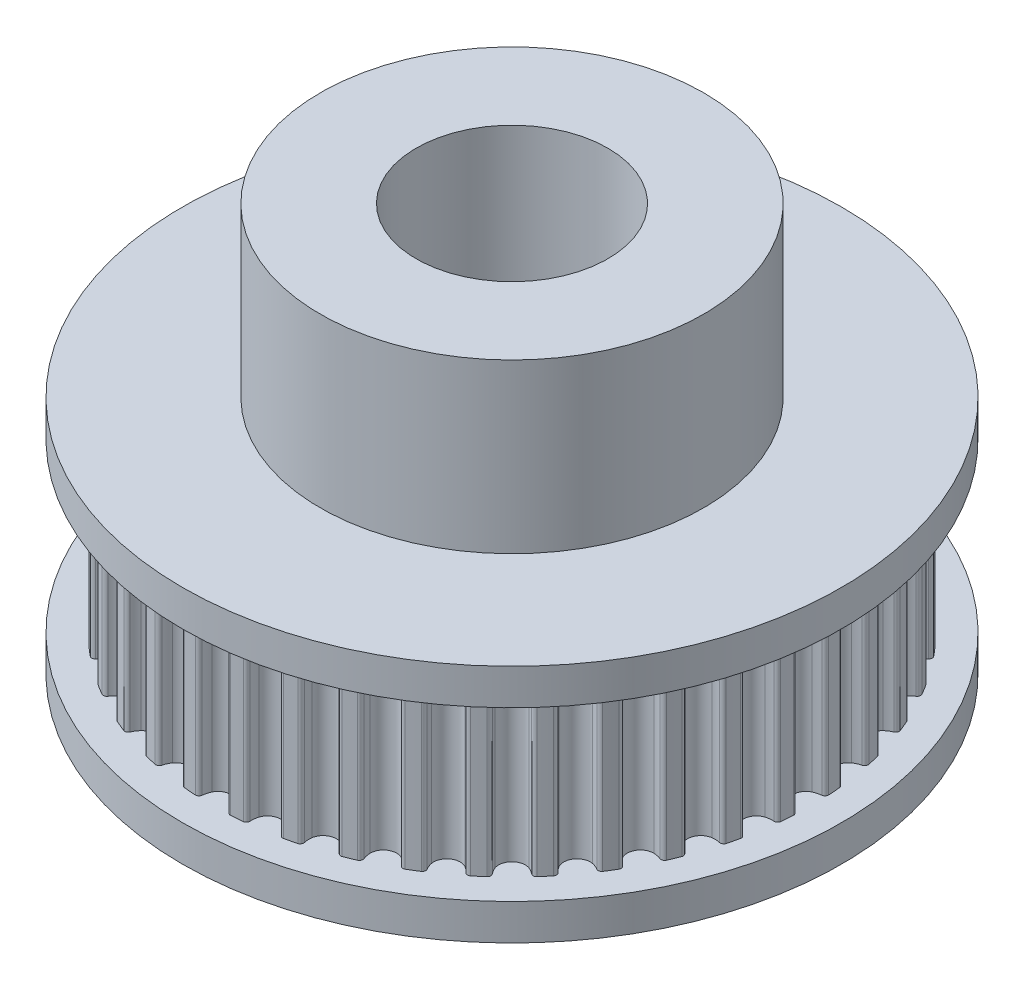
from build123d import *

# Parameters (mm, degrees)
SKETCH2_R           = 4
BOSS_EXTRUDE1_DEPTH = 7


with BuildPart() as part:
    # Sketch1 → Revolve1 (revolve)
    with BuildSketch(Plane.XY):
        Polygon((4, 0), (4, 17), (8, 17), (8, 10), (13.75, 10), (13.75, 8.5), (9.193020022, 8.5), (9.193020022, 1.5), (13.75, 1.5), (13.75, 0), align=None)
    revolve(axis=Axis((0, 0, 0), (0, 1, 0)))

    # Sketch2 → Boss-Extrude1 (add)
    with BuildSketch(Plane(origin=(0, 1.5, 0), x_dir=(1, 0, 0), z_dir=(0, 1, 0))):
        with BuildLine():
            ThreePointArc((12.479630426, -0.730339012), (12.442347251, -0.63136985), (12.349031565, -0.581599248))
            ThreePointArc((12.349031565, -0.581599248), (12.183508148, -0.552656072), (12.025167851, -0.496406098))
            ThreePointArc((12.025167851, -0.496406098), (11.801260646, -0.291780184), (11.718372011, 0))
            ThreePointArc((11.718372011, 0), (11.801260646, 0.291780184), (12.025167851, 0.496406098))
            ThreePointArc((12.025167851, 0.496406098), (12.183508148, 0.552656072), (12.349031565, 0.581599248))
            ThreePointArc((12.349031565, 0.581599248), (12.442347251, 0.63136985), (12.479630426, 0.730339012))
            ThreePointArc((12.479630426, 0.730339012), (12.462450985, 0.980816164), (12.44023566, 1.230896983))
            ThreePointArc((12.44023566, 1.230896983), (12.387929315, 1.322815296), (12.287976662, 1.357375351))
            ThreePointArc((12.287976662, 1.357375351), (12.119963402, 1.360068621), (11.954773103, 1.390856184))
            ThreePointArc((11.954773103, 1.390856184), (11.701612021, 1.557936011), (11.574099406, 1.833157257))
            ThreePointArc((11.574099406, 1.833157257), (11.610323068, 2.134311781), (11.799463058, 2.371445215))
            ThreePointArc((11.799463058, 2.371445215), (11.947054488, 2.451772538), (12.106012327, 2.506252943))
            ThreePointArc((12.106012327, 2.506252943), (12.190393305, 2.570008576), (12.211735274, 2.673591637))
            ThreePointArc((12.211735274, 2.673591637), (12.155584081, 2.918297542), (12.094521004, 3.161824209))
            ThreePointArc((12.094521004, 3.161824209), (12.028479445, 3.24442834), (11.924350992, 3.262926863))
            ThreePointArc((11.924350992, 3.262926863), (11.757984934, 3.23930391), (11.590012165, 3.243870972))
            ThreePointArc((11.590012165, 3.243870972), (11.313830873, 3.36929065), (11.144834061, 3.621176098))
            ThreePointArc((11.144834061, 3.621176098), (11.133500803, 3.92428954), (11.283216324, 4.188091481))
            ThreePointArc((11.283216324, 4.188091481), (11.416424697, 4.290518228), (11.564902888, 4.369194372))
            ThreePointArc((11.564902888, 4.369194372), (11.638271418, 4.445365161), (11.643146672, 4.551011562))
            ThreePointArc((11.643146672, 4.551011562), (11.549406355, 4.78392075), (11.450999102, 5.014896829))
            ThreePointArc((11.450999102, 5.014896829), (11.372848491, 5.086152791), (11.267108225, 5.088134287))
            ThreePointArc((11.267108225, 5.088134287), (11.106485854, 5.038776787), (10.939866663, 5.01701089))
            ThreePointArc((10.939866663, 5.01701089), (10.647465661, 5.097682171), (10.441145914, 5.320029565))
            ThreePointArc((10.441145914, 5.320029565), (10.382534798, 5.617638266), (10.489139358, 5.901613034))
            ThreePointArc((10.489139358, 5.901613034), (10.604684641, 6.023617119), (10.739027159, 6.124551736))
            ThreePointArc((10.739027159, 6.124551736), (10.799576663, 6.211262102), (10.787865156, 6.316370479))
            ThreePointArc((10.787865156, 6.316370479), (10.658843915, 6.531747952), (10.525515599, 6.744486046))
            ThreePointArc((10.525515599, 6.744486046), (10.437180263, 6.80263928), (10.332431861, 6.788054959))
            ThreePointArc((10.332431861, 6.788054959), (10.181508232, 6.714178256), (10.020345336, 6.66661535))
            ThreePointArc((10.020345336, 6.66661535), (9.718924507, 6.700551839), (9.480362103, 6.887886249))
            ThreePointArc((9.480362103, 6.887886249), (9.375916329, 7.172662093), (9.436784968, 7.469817289))
            ThreePointArc((9.436784968, 7.469817289), (9.531822054, 7.608394565), (9.64872094, 7.72910231))
            ThreePointArc((9.64872094, 7.72910231), (9.694960489, 7.824217157), (9.666950598, 7.926199391))
            ThreePointArc((9.666950598, 7.926199391), (9.505825362, 8.118741841), (9.340858969, 8.308003633))
            ThreePointArc((9.340858969, 8.308003633), (9.244514018, 8.351622213), (9.143336733, 8.320831189))
            ThreePointArc((9.143336733, 8.320831189), (9.005828086, 8.224254374), (8.854089851, 8.152065614))
            ThreePointArc((8.854089851, 8.152065614), (8.551071176, 8.138431683), (8.286140313, 8.286140313))
            ThreePointArc((8.286140313, 8.286140313), (8.138431683, 8.551071176), (8.152065614, 8.854089851))
            ThreePointArc((8.152065614, 8.854089851), (8.224254374, 9.005828086), (8.320831189, 9.143336733))
            ThreePointArc((8.320831189, 9.143336733), (8.351622213, 9.244514018), (8.308003633, 9.340858969))
            ThreePointArc((8.308003633, 9.340858969), (8.118741841, 9.505825362), (7.926199391, 9.666950598))
            ThreePointArc((7.926199391, 9.666950598), (7.824217157, 9.694960489), (7.72910231, 9.64872094))
            ThreePointArc((7.72910231, 9.64872094), (7.608394565, 9.531822054), (7.469817289, 9.436784968))
            ThreePointArc((7.469817289, 9.436784968), (7.172662093, 9.375916329), (6.887886249, 9.480362103))
            ThreePointArc((6.887886249, 9.480362103), (6.700551839, 9.718924507), (6.66661535, 10.020345336))
            ThreePointArc((6.66661535, 10.020345336), (6.714178256, 10.181508232), (6.788054959, 10.332431861))
            ThreePointArc((6.788054959, 10.332431861), (6.80263928, 10.437180263), (6.744486046, 10.525515599))
            ThreePointArc((6.744486046, 10.525515599), (6.531747952, 10.658843915), (6.316370479, 10.787865156))
            ThreePointArc((6.316370479, 10.787865156), (6.211262102, 10.799576663), (6.124551736, 10.739027159))
            ThreePointArc((6.124551736, 10.739027159), (6.023617119, 10.604684641), (5.901613034, 10.489139358))
            ThreePointArc((5.901613034, 10.489139358), (5.617638266, 10.382534798), (5.320029565, 10.441145914))
            ThreePointArc((5.320029565, 10.441145914), (5.097682171, 10.647465661), (5.01701089, 10.939866663))
            ThreePointArc((5.01701089, 10.939866663), (5.038776787, 11.106485854), (5.088134287, 11.267108225))
            ThreePointArc((5.088134287, 11.267108225), (5.086152791, 11.372848491), (5.014896829, 11.450999102))
            ThreePointArc((5.014896829, 11.450999102), (4.78392075, 11.549406355), (4.551011562, 11.643146672))
            ThreePointArc((4.551011562, 11.643146672), (4.445365161, 11.638271418), (4.369194372, 11.564902888))
            ThreePointArc((4.369194372, 11.564902888), (4.290518228, 11.416424697), (4.188091481, 11.283216324))
            ThreePointArc((4.188091481, 11.283216324), (3.92428954, 11.133500803), (3.621176098, 11.144834061))
            ThreePointArc((3.621176098, 11.144834061), (3.36929065, 11.313830873), (3.243870972, 11.590012165))
            ThreePointArc((3.243870972, 11.590012165), (3.23930391, 11.757984934), (3.262926863, 11.924350992))
            ThreePointArc((3.262926863, 11.924350992), (3.24442834, 12.028479445), (3.161824209, 12.094521004))
            ThreePointArc((3.161824209, 12.094521004), (2.918297542, 12.155584081), (2.673591637, 12.211735274))
            ThreePointArc((2.673591637, 12.211735274), (2.570008576, 12.190393305), (2.506252943, 12.106012327))
            ThreePointArc((2.506252943, 12.106012327), (2.451772538, 11.947054488), (2.371445215, 11.799463058))
            ThreePointArc((2.371445215, 11.799463058), (2.134311781, 11.610323068), (1.833157257, 11.574099406))
            ThreePointArc((1.833157257, 11.574099406), (1.557936011, 11.701612021), (1.390856184, 11.954773103))
            ThreePointArc((1.390856184, 11.954773103), (1.360068621, 12.119963402), (1.357375351, 12.287976662))
            ThreePointArc((1.357375351, 12.287976662), (1.322815296, 12.387929315), (1.230896983, 12.44023566))
            ThreePointArc((1.230896983, 12.44023566), (0.980816164, 12.462450985), (0.730339012, 12.479630426))
            ThreePointArc((0.730339012, 12.479630426), (0.63136985, 12.442347251), (0.581599248, 12.349031565))
            ThreePointArc((0.581599248, 12.349031565), (0.552656072, 12.183508148), (0.496406098, 12.025167851))
            ThreePointArc((0.496406098, 12.025167851), (0.291780184, 11.801260646), (0, 11.718372011))
            ThreePointArc((0, 11.718372011), (-0.291780184, 11.801260646), (-0.496406098, 12.025167851))
            ThreePointArc((-0.496406098, 12.025167851), (-0.552656072, 12.183508148), (-0.581599248, 12.349031565))
            ThreePointArc((-0.581599248, 12.349031565), (-0.63136985, 12.442347251), (-0.730339012, 12.479630426))
            ThreePointArc((-0.730339012, 12.479630426), (-0.980816164, 12.462450985), (-1.230896983, 12.44023566))
            ThreePointArc((-1.230896983, 12.44023566), (-1.322815296, 12.387929315), (-1.357375351, 12.287976662))
            ThreePointArc((-1.357375351, 12.287976662), (-1.360068621, 12.119963402), (-1.390856184, 11.954773103))
            ThreePointArc((-1.390856184, 11.954773103), (-1.557936011, 11.701612021), (-1.833157257, 11.574099406))
            ThreePointArc((-1.833157257, 11.574099406), (-2.134311781, 11.610323068), (-2.371445215, 11.799463058))
            ThreePointArc((-2.371445215, 11.799463058), (-2.451772538, 11.947054488), (-2.506252943, 12.106012327))
            ThreePointArc((-2.506252943, 12.106012327), (-2.570008576, 12.190393305), (-2.673591637, 12.211735274))
            ThreePointArc((-2.673591637, 12.211735274), (-2.918297542, 12.155584081), (-3.161824209, 12.094521004))
            ThreePointArc((-3.161824209, 12.094521004), (-3.24442834, 12.028479445), (-3.262926863, 11.924350992))
            ThreePointArc((-3.262926863, 11.924350992), (-3.23930391, 11.757984934), (-3.243870972, 11.590012165))
            ThreePointArc((-3.243870972, 11.590012165), (-3.36929065, 11.313830873), (-3.621176098, 11.144834061))
            ThreePointArc((-3.621176098, 11.144834061), (-3.92428954, 11.133500803), (-4.188091481, 11.283216324))
            ThreePointArc((-4.188091481, 11.283216324), (-4.290518228, 11.416424697), (-4.369194372, 11.564902888))
            ThreePointArc((-4.369194372, 11.564902888), (-4.445365161, 11.638271418), (-4.551011562, 11.643146672))
            ThreePointArc((-4.551011562, 11.643146672), (-4.78392075, 11.549406355), (-5.014896829, 11.450999102))
            ThreePointArc((-5.014896829, 11.450999102), (-5.086152791, 11.372848491), (-5.088134287, 11.267108225))
            ThreePointArc((-5.088134287, 11.267108225), (-5.038776787, 11.106485854), (-5.01701089, 10.939866663))
            ThreePointArc((-5.01701089, 10.939866663), (-5.097682171, 10.647465661), (-5.320029565, 10.441145914))
            ThreePointArc((-5.320029565, 10.441145914), (-5.617638266, 10.382534798), (-5.901613034, 10.489139358))
            ThreePointArc((-5.901613034, 10.489139358), (-6.023617119, 10.604684641), (-6.124551736, 10.739027159))
            ThreePointArc((-6.124551736, 10.739027159), (-6.211262102, 10.799576663), (-6.316370479, 10.787865156))
            ThreePointArc((-6.316370479, 10.787865156), (-6.531747952, 10.658843915), (-6.744486046, 10.525515599))
            ThreePointArc((-6.744486046, 10.525515599), (-6.80263928, 10.437180263), (-6.788054959, 10.332431861))
            ThreePointArc((-6.788054959, 10.332431861), (-6.714178256, 10.181508232), (-6.66661535, 10.020345336))
            ThreePointArc((-6.66661535, 10.020345336), (-6.700551839, 9.718924507), (-6.887886249, 9.480362103))
            ThreePointArc((-6.887886249, 9.480362103), (-7.172662093, 9.375916329), (-7.469817289, 9.436784968))
            ThreePointArc((-7.469817289, 9.436784968), (-7.608394565, 9.531822054), (-7.72910231, 9.64872094))
            ThreePointArc((-7.72910231, 9.64872094), (-7.824217157, 9.694960489), (-7.926199391, 9.666950598))
            ThreePointArc((-7.926199391, 9.666950598), (-8.118741841, 9.505825362), (-8.308003633, 9.340858969))
            ThreePointArc((-8.308003633, 9.340858969), (-8.351622213, 9.244514018), (-8.320831189, 9.143336733))
            ThreePointArc((-8.320831189, 9.143336733), (-8.224254374, 9.005828086), (-8.152065614, 8.854089851))
            ThreePointArc((-8.152065614, 8.854089851), (-8.138431683, 8.551071176), (-8.286140313, 8.286140313))
            ThreePointArc((-8.286140313, 8.286140313), (-8.551071176, 8.138431683), (-8.854089851, 8.152065614))
            ThreePointArc((-8.854089851, 8.152065614), (-9.005828086, 8.224254374), (-9.143336733, 8.320831189))
            ThreePointArc((-9.143336733, 8.320831189), (-9.244514018, 8.351622213), (-9.340858969, 8.308003633))
            ThreePointArc((-9.340858969, 8.308003633), (-9.505825362, 8.118741841), (-9.666950598, 7.926199391))
            ThreePointArc((-9.666950598, 7.926199391), (-9.694960489, 7.824217157), (-9.64872094, 7.72910231))
            ThreePointArc((-9.64872094, 7.72910231), (-9.531822054, 7.608394565), (-9.436784968, 7.469817289))
            ThreePointArc((-9.436784968, 7.469817289), (-9.375916329, 7.172662093), (-9.480362103, 6.887886249))
            ThreePointArc((-9.480362103, 6.887886249), (-9.718924507, 6.700551839), (-10.020345336, 6.66661535))
            ThreePointArc((-10.020345336, 6.66661535), (-10.181508232, 6.714178256), (-10.332431861, 6.788054959))
            ThreePointArc((-10.332431861, 6.788054959), (-10.437180263, 6.80263928), (-10.525515599, 6.744486046))
            ThreePointArc((-10.525515599, 6.744486046), (-10.658843915, 6.531747952), (-10.787865156, 6.316370479))
            ThreePointArc((-10.787865156, 6.316370479), (-10.799576663, 6.211262102), (-10.739027159, 6.124551736))
            ThreePointArc((-10.739027159, 6.124551736), (-10.604684641, 6.023617119), (-10.489139358, 5.901613034))
            ThreePointArc((-10.489139358, 5.901613034), (-10.382534798, 5.617638266), (-10.441145914, 5.320029565))
            ThreePointArc((-10.441145914, 5.320029565), (-10.647465661, 5.097682171), (-10.939866663, 5.01701089))
            ThreePointArc((-10.939866663, 5.01701089), (-11.106485854, 5.038776787), (-11.267108225, 5.088134287))
            ThreePointArc((-11.267108225, 5.088134287), (-11.372848491, 5.086152791), (-11.450999102, 5.014896829))
            ThreePointArc((-11.450999102, 5.014896829), (-11.549406355, 4.78392075), (-11.643146672, 4.551011562))
            ThreePointArc((-11.643146672, 4.551011562), (-11.638271418, 4.445365161), (-11.564902888, 4.369194372))
            ThreePointArc((-11.564902888, 4.369194372), (-11.416424697, 4.290518228), (-11.283216324, 4.188091481))
            ThreePointArc((-11.283216324, 4.188091481), (-11.133500803, 3.92428954), (-11.144834061, 3.621176098))
            ThreePointArc((-11.144834061, 3.621176098), (-11.313830873, 3.36929065), (-11.590012165, 3.243870972))
            ThreePointArc((-11.590012165, 3.243870972), (-11.757984934, 3.23930391), (-11.924350992, 3.262926863))
            ThreePointArc((-11.924350992, 3.262926863), (-12.028479445, 3.24442834), (-12.094521004, 3.161824209))
            ThreePointArc((-12.094521004, 3.161824209), (-12.155584081, 2.918297542), (-12.211735274, 2.673591637))
            ThreePointArc((-12.211735274, 2.673591637), (-12.190393305, 2.570008576), (-12.106012327, 2.506252943))
            ThreePointArc((-12.106012327, 2.506252943), (-11.947054488, 2.451772538), (-11.799463058, 2.371445215))
            ThreePointArc((-11.799463058, 2.371445215), (-11.610323068, 2.134311781), (-11.574099406, 1.833157257))
            ThreePointArc((-11.574099406, 1.833157257), (-11.701612021, 1.557936011), (-11.954773103, 1.390856184))
            ThreePointArc((-11.954773103, 1.390856184), (-12.119963402, 1.360068621), (-12.287976662, 1.357375351))
            ThreePointArc((-12.287976662, 1.357375351), (-12.387929315, 1.322815296), (-12.44023566, 1.230896983))
            ThreePointArc((-12.44023566, 1.230896983), (-12.462450985, 0.980816164), (-12.479630426, 0.730339012))
            ThreePointArc((-12.479630426, 0.730339012), (-12.442347251, 0.63136985), (-12.349031565, 0.581599248))
            ThreePointArc((-12.349031565, 0.581599248), (-12.183508148, 0.552656072), (-12.025167851, 0.496406098))
            ThreePointArc((-12.025167851, 0.496406098), (-11.801260646, 0.291780184), (-11.718372011, 0))
            ThreePointArc((-11.718372011, 0), (-11.801260646, -0.291780184), (-12.025167851, -0.496406098))
            ThreePointArc((-12.025167851, -0.496406098), (-12.183508148, -0.552656072), (-12.349031565, -0.581599248))
            ThreePointArc((-12.349031565, -0.581599248), (-12.442347251, -0.63136985), (-12.479630426, -0.730339012))
            ThreePointArc((-12.479630426, -0.730339012), (-12.462450985, -0.980816164), (-12.44023566, -1.230896983))
            ThreePointArc((-12.44023566, -1.230896983), (-12.387929315, -1.322815296), (-12.287976662, -1.357375351))
            ThreePointArc((-12.287976662, -1.357375351), (-12.119963402, -1.360068621), (-11.954773103, -1.390856184))
            ThreePointArc((-11.954773103, -1.390856184), (-11.701612021, -1.557936011), (-11.574099406, -1.833157257))
            ThreePointArc((-11.574099406, -1.833157257), (-11.610323068, -2.134311781), (-11.799463058, -2.371445215))
            ThreePointArc((-11.799463058, -2.371445215), (-11.947054488, -2.451772538), (-12.106012327, -2.506252943))
            ThreePointArc((-12.106012327, -2.506252943), (-12.190393305, -2.570008576), (-12.211735274, -2.673591637))
            ThreePointArc((-12.211735274, -2.673591637), (-12.155584081, -2.918297542), (-12.094521004, -3.161824209))
            ThreePointArc((-12.094521004, -3.161824209), (-12.028479445, -3.24442834), (-11.924350992, -3.262926863))
            ThreePointArc((-11.924350992, -3.262926863), (-11.757984934, -3.23930391), (-11.590012165, -3.243870972))
            ThreePointArc((-11.590012165, -3.243870972), (-11.313830873, -3.36929065), (-11.144834061, -3.621176098))
            ThreePointArc((-11.144834061, -3.621176098), (-11.133500803, -3.92428954), (-11.283216324, -4.188091481))
            ThreePointArc((-11.283216324, -4.188091481), (-11.416424697, -4.290518228), (-11.564902888, -4.369194372))
            ThreePointArc((-11.564902888, -4.369194372), (-11.638271418, -4.445365161), (-11.643146672, -4.551011562))
            ThreePointArc((-11.643146672, -4.551011562), (-11.549406355, -4.78392075), (-11.450999102, -5.014896829))
            ThreePointArc((-11.450999102, -5.014896829), (-11.372848491, -5.086152791), (-11.267108225, -5.088134287))
            ThreePointArc((-11.267108225, -5.088134287), (-11.106485854, -5.038776787), (-10.939866663, -5.01701089))
            ThreePointArc((-10.939866663, -5.01701089), (-10.647465661, -5.097682171), (-10.441145914, -5.320029565))
            ThreePointArc((-10.441145914, -5.320029565), (-10.382534798, -5.617638266), (-10.489139358, -5.901613034))
            ThreePointArc((-10.489139358, -5.901613034), (-10.604684641, -6.023617119), (-10.739027159, -6.124551736))
            ThreePointArc((-10.739027159, -6.124551736), (-10.799576663, -6.211262102), (-10.787865156, -6.316370479))
            ThreePointArc((-10.787865156, -6.316370479), (-10.658843915, -6.531747952), (-10.525515599, -6.744486046))
            ThreePointArc((-10.525515599, -6.744486046), (-10.437180263, -6.80263928), (-10.332431861, -6.788054959))
            ThreePointArc((-10.332431861, -6.788054959), (-10.181508232, -6.714178256), (-10.020345336, -6.66661535))
            ThreePointArc((-10.020345336, -6.66661535), (-9.718924507, -6.700551839), (-9.480362103, -6.887886249))
            ThreePointArc((-9.480362103, -6.887886249), (-9.375916329, -7.172662093), (-9.436784968, -7.469817289))
            ThreePointArc((-9.436784968, -7.469817289), (-9.531822054, -7.608394565), (-9.64872094, -7.72910231))
            ThreePointArc((-9.64872094, -7.72910231), (-9.694960489, -7.824217157), (-9.666950598, -7.926199391))
            ThreePointArc((-9.666950598, -7.926199391), (-9.505825362, -8.118741841), (-9.340858969, -8.308003633))
            ThreePointArc((-9.340858969, -8.308003633), (-9.244514018, -8.351622213), (-9.143336733, -8.320831189))
            ThreePointArc((-9.143336733, -8.320831189), (-9.005828086, -8.224254374), (-8.854089851, -8.152065614))
            ThreePointArc((-8.854089851, -8.152065614), (-8.551071176, -8.138431683), (-8.286140313, -8.286140313))
            ThreePointArc((-8.286140313, -8.286140313), (-8.138431683, -8.551071176), (-8.152065614, -8.854089851))
            ThreePointArc((-8.152065614, -8.854089851), (-8.224254374, -9.005828086), (-8.320831189, -9.143336733))
            ThreePointArc((-8.320831189, -9.143336733), (-8.351622213, -9.244514018), (-8.308003633, -9.340858969))
            ThreePointArc((-8.308003633, -9.340858969), (-8.118741841, -9.505825362), (-7.926199391, -9.666950598))
            ThreePointArc((-7.926199391, -9.666950598), (-7.824217157, -9.694960489), (-7.72910231, -9.64872094))
            ThreePointArc((-7.72910231, -9.64872094), (-7.608394565, -9.531822054), (-7.469817289, -9.436784968))
            ThreePointArc((-7.469817289, -9.436784968), (-7.172662093, -9.375916329), (-6.887886249, -9.480362103))
            ThreePointArc((-6.887886249, -9.480362103), (-6.700551839, -9.718924507), (-6.66661535, -10.020345336))
            ThreePointArc((-6.66661535, -10.020345336), (-6.714178256, -10.181508232), (-6.788054959, -10.332431861))
            ThreePointArc((-6.788054959, -10.332431861), (-6.80263928, -10.437180263), (-6.744486046, -10.525515599))
            ThreePointArc((-6.744486046, -10.525515599), (-6.531747952, -10.658843915), (-6.316370479, -10.787865156))
            ThreePointArc((-6.316370479, -10.787865156), (-6.211262102, -10.799576663), (-6.124551736, -10.739027159))
            ThreePointArc((-6.124551736, -10.739027159), (-6.023617119, -10.604684641), (-5.901613034, -10.489139358))
            ThreePointArc((-5.901613034, -10.489139358), (-5.617638266, -10.382534798), (-5.320029565, -10.441145914))
            ThreePointArc((-5.320029565, -10.441145914), (-5.097682171, -10.647465661), (-5.01701089, -10.939866663))
            ThreePointArc((-5.01701089, -10.939866663), (-5.038776787, -11.106485854), (-5.088134287, -11.267108225))
            ThreePointArc((-5.088134287, -11.267108225), (-5.086152791, -11.372848491), (-5.014896829, -11.450999102))
            ThreePointArc((-5.014896829, -11.450999102), (-4.78392075, -11.549406355), (-4.551011562, -11.643146672))
            ThreePointArc((-4.551011562, -11.643146672), (-4.445365161, -11.638271418), (-4.369194372, -11.564902888))
            ThreePointArc((-4.369194372, -11.564902888), (-4.290518228, -11.416424697), (-4.188091481, -11.283216324))
            ThreePointArc((-4.188091481, -11.283216324), (-3.92428954, -11.133500803), (-3.621176098, -11.144834061))
            ThreePointArc((-3.621176098, -11.144834061), (-3.36929065, -11.313830873), (-3.243870972, -11.590012165))
            ThreePointArc((-3.243870972, -11.590012165), (-3.23930391, -11.757984934), (-3.262926863, -11.924350992))
            ThreePointArc((-3.262926863, -11.924350992), (-3.24442834, -12.028479445), (-3.161824209, -12.094521004))
            ThreePointArc((-3.161824209, -12.094521004), (-2.918297542, -12.155584081), (-2.673591637, -12.211735274))
            ThreePointArc((-2.673591637, -12.211735274), (-2.570008576, -12.190393305), (-2.506252943, -12.106012327))
            ThreePointArc((-2.506252943, -12.106012327), (-2.451772538, -11.947054488), (-2.371445215, -11.799463058))
            ThreePointArc((-2.371445215, -11.799463058), (-2.134311781, -11.610323068), (-1.833157257, -11.574099406))
            ThreePointArc((-1.833157257, -11.574099406), (-1.557936011, -11.701612021), (-1.390856184, -11.954773103))
            ThreePointArc((-1.390856184, -11.954773103), (-1.360068621, -12.119963402), (-1.357375351, -12.287976662))
            ThreePointArc((-1.357375351, -12.287976662), (-1.322815296, -12.387929315), (-1.230896983, -12.44023566))
            ThreePointArc((-1.230896983, -12.44023566), (-0.980816164, -12.462450985), (-0.730339012, -12.479630426))
            ThreePointArc((-0.730339012, -12.479630426), (-0.63136985, -12.442347251), (-0.581599248, -12.349031565))
            ThreePointArc((-0.581599248, -12.349031565), (-0.552656072, -12.183508148), (-0.496406098, -12.025167851))
            ThreePointArc((-0.496406098, -12.025167851), (-0.291780184, -11.801260646), (0, -11.718372011))
            ThreePointArc((0, -11.718372011), (0.291780184, -11.801260646), (0.496406098, -12.025167851))
            ThreePointArc((0.496406098, -12.025167851), (0.552656072, -12.183508148), (0.581599248, -12.349031565))
            ThreePointArc((0.581599248, -12.349031565), (0.63136985, -12.442347251), (0.730339012, -12.479630426))
            ThreePointArc((0.730339012, -12.479630426), (0.980816164, -12.462450985), (1.230896983, -12.44023566))
            ThreePointArc((1.230896983, -12.44023566), (1.322815296, -12.387929315), (1.357375351, -12.287976662))
            ThreePointArc((1.357375351, -12.287976662), (1.360068621, -12.119963402), (1.390856184, -11.954773103))
            ThreePointArc((1.390856184, -11.954773103), (1.557936011, -11.701612021), (1.833157257, -11.574099406))
            ThreePointArc((1.833157257, -11.574099406), (2.134311781, -11.610323068), (2.371445215, -11.799463058))
            ThreePointArc((2.371445215, -11.799463058), (2.451772538, -11.947054488), (2.506252943, -12.106012327))
            ThreePointArc((2.506252943, -12.106012327), (2.570008576, -12.190393305), (2.673591637, -12.211735274))
            ThreePointArc((2.673591637, -12.211735274), (2.918297542, -12.155584081), (3.161824209, -12.094521004))
            ThreePointArc((3.161824209, -12.094521004), (3.24442834, -12.028479445), (3.262926863, -11.924350992))
            ThreePointArc((3.262926863, -11.924350992), (3.23930391, -11.757984934), (3.243870972, -11.590012165))
            ThreePointArc((3.243870972, -11.590012165), (3.36929065, -11.313830873), (3.621176098, -11.144834061))
            ThreePointArc((3.621176098, -11.144834061), (3.92428954, -11.133500803), (4.188091481, -11.283216324))
            ThreePointArc((4.188091481, -11.283216324), (4.290518228, -11.416424697), (4.369194372, -11.564902888))
            ThreePointArc((4.369194372, -11.564902888), (4.445365161, -11.638271418), (4.551011562, -11.643146672))
            ThreePointArc((4.551011562, -11.643146672), (4.78392075, -11.549406355), (5.014896829, -11.450999102))
            ThreePointArc((5.014896829, -11.450999102), (5.086152791, -11.372848491), (5.088134287, -11.267108225))
            ThreePointArc((5.088134287, -11.267108225), (5.038776787, -11.106485854), (5.01701089, -10.939866663))
            ThreePointArc((5.01701089, -10.939866663), (5.097682171, -10.647465661), (5.320029565, -10.441145914))
            ThreePointArc((5.320029565, -10.441145914), (5.617638266, -10.382534798), (5.901613034, -10.489139358))
            ThreePointArc((5.901613034, -10.489139358), (6.023617119, -10.604684641), (6.124551736, -10.739027159))
            ThreePointArc((6.124551736, -10.739027159), (6.211262102, -10.799576663), (6.316370479, -10.787865156))
            ThreePointArc((6.316370479, -10.787865156), (6.531747952, -10.658843915), (6.744486046, -10.525515599))
            ThreePointArc((6.744486046, -10.525515599), (6.80263928, -10.437180263), (6.788054959, -10.332431861))
            ThreePointArc((6.788054959, -10.332431861), (6.714178256, -10.181508232), (6.66661535, -10.020345336))
            ThreePointArc((6.66661535, -10.020345336), (6.700551839, -9.718924507), (6.887886249, -9.480362103))
            ThreePointArc((6.887886249, -9.480362103), (7.172662093, -9.375916329), (7.469817289, -9.436784968))
            ThreePointArc((7.469817289, -9.436784968), (7.608394565, -9.531822054), (7.72910231, -9.64872094))
            ThreePointArc((7.72910231, -9.64872094), (7.824217157, -9.694960489), (7.926199391, -9.666950598))
            ThreePointArc((7.926199391, -9.666950598), (8.118741841, -9.505825362), (8.308003633, -9.340858969))
            ThreePointArc((8.308003633, -9.340858969), (8.351622213, -9.244514018), (8.320831189, -9.143336733))
            ThreePointArc((8.320831189, -9.143336733), (8.224254374, -9.005828086), (8.152065614, -8.854089851))
            ThreePointArc((8.152065614, -8.854089851), (8.138431683, -8.551071176), (8.286140313, -8.286140313))
            ThreePointArc((8.286140313, -8.286140313), (8.551071176, -8.138431683), (8.854089851, -8.152065614))
            ThreePointArc((8.854089851, -8.152065614), (9.005828086, -8.224254374), (9.143336733, -8.320831189))
            ThreePointArc((9.143336733, -8.320831189), (9.244514018, -8.351622213), (9.340858969, -8.308003633))
            ThreePointArc((9.340858969, -8.308003633), (9.505825362, -8.118741841), (9.666950598, -7.926199391))
            ThreePointArc((9.666950598, -7.926199391), (9.694960489, -7.824217157), (9.64872094, -7.72910231))
            ThreePointArc((9.64872094, -7.72910231), (9.531822054, -7.608394565), (9.436784968, -7.469817289))
            ThreePointArc((9.436784968, -7.469817289), (9.375916329, -7.172662093), (9.480362103, -6.887886249))
            ThreePointArc((9.480362103, -6.887886249), (9.718924507, -6.700551839), (10.020345336, -6.66661535))
            ThreePointArc((10.020345336, -6.66661535), (10.181508232, -6.714178256), (10.332431861, -6.788054959))
            ThreePointArc((10.332431861, -6.788054959), (10.437180263, -6.80263928), (10.525515599, -6.744486046))
            ThreePointArc((10.525515599, -6.744486046), (10.658843915, -6.531747952), (10.787865156, -6.316370479))
            ThreePointArc((10.787865156, -6.316370479), (10.799576663, -6.211262102), (10.739027159, -6.124551736))
            ThreePointArc((10.739027159, -6.124551736), (10.604684641, -6.023617119), (10.489139358, -5.901613034))
            ThreePointArc((10.489139358, -5.901613034), (10.382534798, -5.617638266), (10.441145914, -5.320029565))
            ThreePointArc((10.441145914, -5.320029565), (10.647465661, -5.097682171), (10.939866663, -5.01701089))
            ThreePointArc((10.939866663, -5.01701089), (11.106485854, -5.038776787), (11.267108225, -5.088134287))
            ThreePointArc((11.267108225, -5.088134287), (11.372848491, -5.086152791), (11.450999102, -5.014896829))
            ThreePointArc((11.450999102, -5.014896829), (11.549406355, -4.78392075), (11.643146672, -4.551011562))
            ThreePointArc((11.643146672, -4.551011562), (11.638271418, -4.445365161), (11.564902888, -4.369194372))
            ThreePointArc((11.564902888, -4.369194372), (11.416424697, -4.290518228), (11.283216324, -4.188091481))
            ThreePointArc((11.283216324, -4.188091481), (11.133500803, -3.92428954), (11.144834061, -3.621176098))
            ThreePointArc((11.144834061, -3.621176098), (11.313830873, -3.36929065), (11.590012165, -3.243870972))
            ThreePointArc((11.590012165, -3.243870972), (11.757984934, -3.23930391), (11.924350992, -3.262926863))
            ThreePointArc((11.924350992, -3.262926863), (12.028479445, -3.24442834), (12.094521004, -3.161824209))
            ThreePointArc((12.094521004, -3.161824209), (12.155584081, -2.918297542), (12.211735274, -2.673591637))
            ThreePointArc((12.211735274, -2.673591637), (12.190393305, -2.570008576), (12.106012327, -2.506252943))
            ThreePointArc((12.106012327, -2.506252943), (11.947054488, -2.451772538), (11.799463058, -2.371445215))
            ThreePointArc((11.799463058, -2.371445215), (11.610323068, -2.134311781), (11.574099406, -1.833157257))
            ThreePointArc((11.574099406, -1.833157257), (11.701612021, -1.557936011), (11.954773103, -1.390856184))
            ThreePointArc((11.954773103, -1.390856184), (12.119963402, -1.360068621), (12.287976662, -1.357375351))
            ThreePointArc((12.287976662, -1.357375351), (12.387929315, -1.322815296), (12.44023566, -1.230896983))
            ThreePointArc((12.44023566, -1.230896983), (12.462450985, -0.980816164), (12.479630426, -0.730339012))
        make_face()
        Circle(SKETCH2_R, mode=Mode.SUBTRACT)
    extrude(amount=BOSS_EXTRUDE1_DEPTH)


solid = part.part
